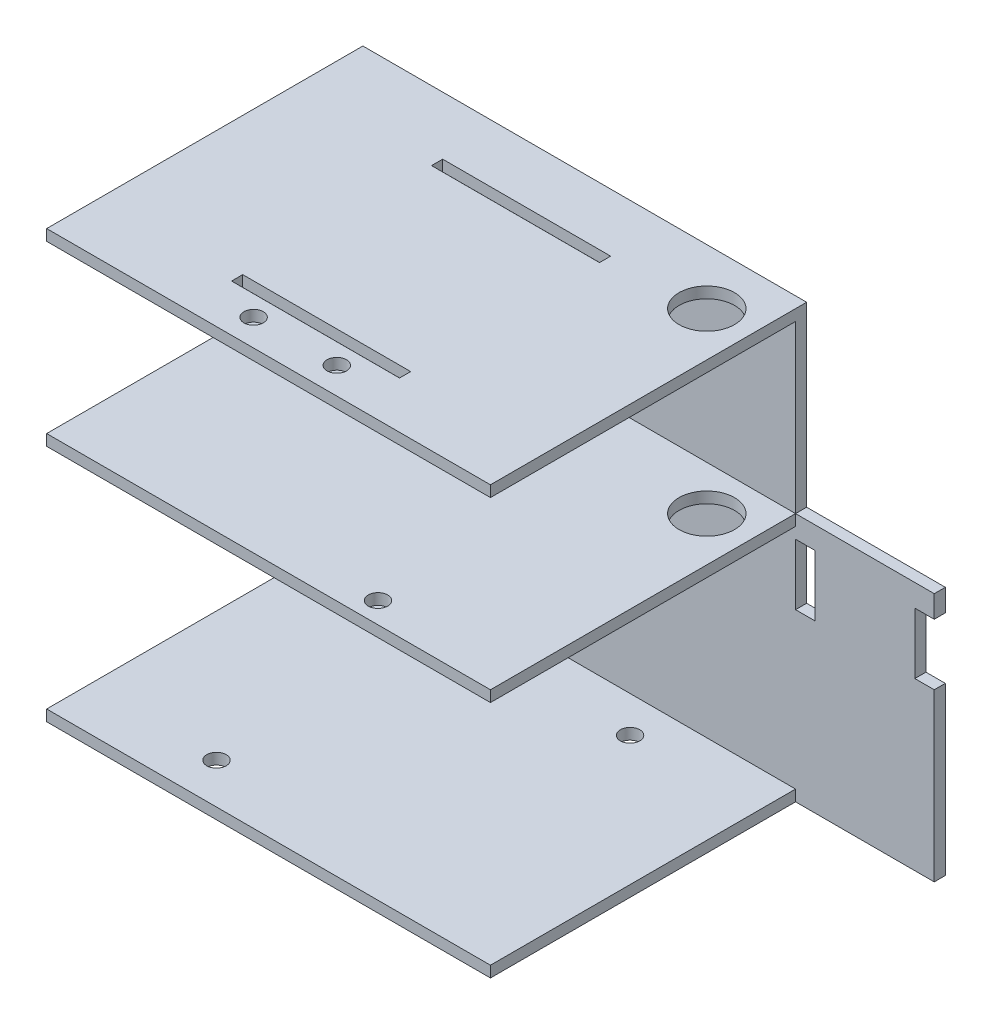
from build123d import *

# Parameters (mm, degrees)
SKETCH1_W           = 130
SKETCH1_H           = 55
BOSS_EXTRUDE1_DEPTH = 2
SKETCH2_W           = 130
SKETCH2_H           = 2
BOSS_EXTRUDE2_DEPTH = 45
SKETCH3_W           = 25
SKETCH3_H           = 55
CUT_EXTRUDE1_DEPTH  = 45
SKETCH4_W           = 3.5
SKETCH4_H           = 11
CUT_EXTRUDE2_DEPTH  = 2
SKETCH6_W           = 80
SKETCH6_H           = 2
BOSS_EXTRUDE3_DEPTH = 55
SKETCH7_R           = 1.75
SKETCH7_R_2         = 5
CUT_EXTRUDE3_DEPTH  = 2
SKETCH8_W           = 80
SKETCH8_H           = 2
BOSS_EXTRUDE4_DEPTH = 30
SKETCH9_W           = 80
SKETCH9_H           = 57
BOSS_EXTRUDE5_DEPTH = 2
SKETCH11_R          = 5
SKETCH11_R_2        = 1.75
SKETCH11_W          = 30.278017406
SKETCH11_H          = 2.009390924
CUT_EXTRUDE4_DEPTH  = 2
SKETCH12_R          = 1.75
CUT_EXTRUDE5_DEPTH  = 2


with BuildPart() as part:
    # Sketch1 → Boss-Extrude1 (new body)
    with BuildSketch(Plane(origin=(0, 0, 0), x_dir=(1, 0, 0), z_dir=(0, 1, 0))):
        Rectangle(SKETCH1_W, SKETCH1_H)
    extrude(amount=BOSS_EXTRUDE1_DEPTH)

    # Sketch2 → Boss-Extrude2 (add)
    with BuildSketch(Plane(origin=(0, 0, 0), x_dir=(1, 0, 0), z_dir=(0, 1, 0))):
        with Locations((0, 28.5)):
            Rectangle(SKETCH2_W, SKETCH2_H)
    extrude(amount=BOSS_EXTRUDE2_DEPTH)

    # Sketch3 → Cut-Extrude1 (cut)
    with BuildSketch(Plane(origin=(0, 2, 0), x_dir=(1, 0, 0), z_dir=(0, 1, 0))):
        with Locations((-52.5, 0)):
            Rectangle(SKETCH3_W, SKETCH3_H)
        with Locations((52.5, 0)):
            Rectangle(SKETCH3_W, SKETCH3_H)
    extrude(amount=-CUT_EXTRUDE1_DEPTH, mode=Mode.SUBTRACT)

    # Sketch4 → Cut-Extrude2 (cut)
    with BuildSketch(Plane.XY.offset(-27.5)):
        with Locations((-63.25, 35.5)):
            Rectangle(SKETCH4_W, SKETCH4_H)
        with Locations((-41.75, 35.5)):
            Rectangle(SKETCH4_W, SKETCH4_H)
        with Locations((41.75, 35.5)):
            Rectangle(SKETCH4_W, SKETCH4_H)
        with Locations((63.25, 35.5)):
            Rectangle(SKETCH4_W, SKETCH4_H)
    extrude(amount=-CUT_EXTRUDE2_DEPTH, mode=Mode.SUBTRACT)

    # Sketch6 → Boss-Extrude3 (add)
    with BuildSketch(Plane.XY.offset(-27.5)):
        with Locations((0, 44)):
            Rectangle(SKETCH6_W, SKETCH6_H)
    extrude(amount=BOSS_EXTRUDE3_DEPTH)

    # Sketch7 → Cut-Extrude3 (cut)
    with BuildSketch(Plane(origin=(0, 45, 0), x_dir=(1, 0, 0), z_dir=(0, 1, 0))):
        with Locations((-35.065858189, 19.292839325)):
            Circle(SKETCH7_R)
        with Locations((15.934141811, -23.707160675)):
            Circle(SKETCH7_R)
        with Locations((32, 19.5)):
            Circle(SKETCH7_R_2)
    extrude(amount=-CUT_EXTRUDE3_DEPTH, mode=Mode.SUBTRACT)

    # Sketch8 → Boss-Extrude4 (add)
    with BuildSketch(Plane(origin=(0, 45, 0), x_dir=(1, 0, 0), z_dir=(0, 1, 0))):
        with Locations((0, 28.5)):
            Rectangle(SKETCH8_W, SKETCH8_H)
    extrude(amount=BOSS_EXTRUDE4_DEPTH)

    # Sketch9 → Boss-Extrude5 (add)
    with BuildSketch(Plane(origin=(0, 75, 0), x_dir=(1, 0, 0), z_dir=(0, 1, 0))):
        with Locations((0, 1)):
            Rectangle(SKETCH9_W, SKETCH9_H)
    extrude(amount=BOSS_EXTRUDE5_DEPTH)

    # Sketch11 → Cut-Extrude4 (cut)
    with BuildSketch(Plane(origin=(0, 77, 0), x_dir=(1, 0, 0), z_dir=(0, 1, 0))):
        with Locations((32, 19.5)):
            Circle(SKETCH11_R)
        with Locations((-7.5, -22.699940475)):
            Circle(SKETCH11_R_2)
        with Locations((7.5, -22.699940475)):
            Circle(SKETCH11_R_2)
        with Locations((0, -18.023076891)):
            Rectangle(SKETCH11_W, SKETCH11_H)
        with Locations((0, 18.023076891)):
            Rectangle(SKETCH11_W, SKETCH11_H)
    extrude(amount=-CUT_EXTRUDE4_DEPTH, mode=Mode.SUBTRACT)

    # Sketch12 → Cut-Extrude5 (cut)
    with BuildSketch(Plane.XZ):
        with Locations((-16.693132279, 20.191612333)):
            Circle(SKETCH12_R)
        with Locations((16.693132279, -20.97095973)):
            Circle(SKETCH12_R)
    extrude(amount=-CUT_EXTRUDE5_DEPTH, mode=Mode.SUBTRACT)


solid = part.part
